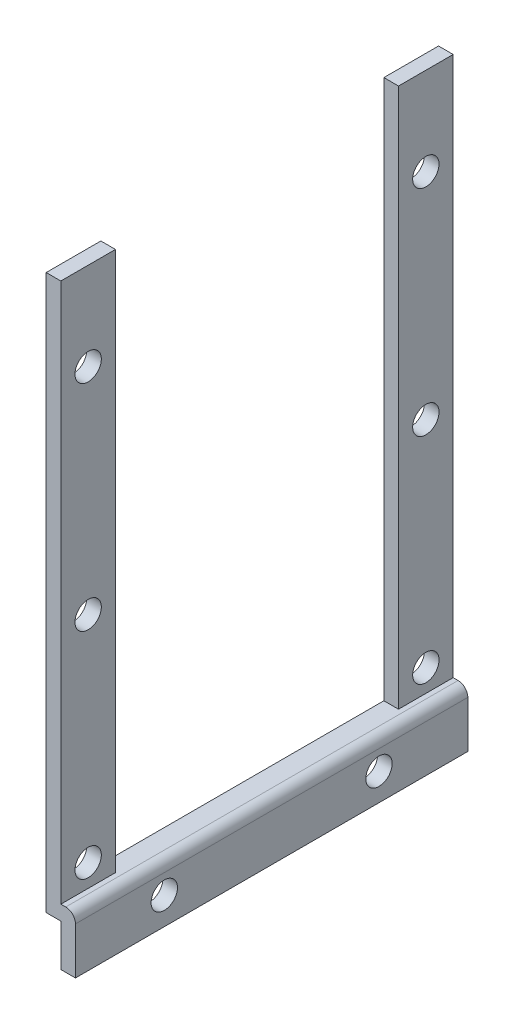
from build123d import *

# Parameters (mm, degrees)
BOSS_EXTRUDE1_DEPTH = 40.2
CUT_EXTRUDE2_REACH  = 3.5
SKETCH3_R           = 1.35
SKETCH3_W           = 29
SKETCH3_H           = 55.3
FILLET1_R           = 1
CUT_EXTRUDE3_REACH  = 5
SKETCH4_R           = 1.35


with BuildPart() as part:
    # Sketch1 → Boss-Extrude1 (new body)
    with BuildSketch(Plane.XY):
        Polygon((0, 0), (0, 4.3), (-1.5, 4.3), (-1.5, 61.1), (0, 61.1), (0, 5.8), (1.5, 5.8), (1.5, 0), align=None)
    extrude(amount=-BOSS_EXTRUDE1_DEPTH)

    # Sketch3 → Cut-Extrude2 (cut, up to next)
    with BuildSketch(Plane(origin=(0, 0, 0), x_dir=(0, 0, -1), z_dir=(1, 0, 0)), mode=Mode.PRIVATE) as cut_extrude2_sk1:
        with Locations((2.8, 8.1)):
            Circle(SKETCH3_R)
    cut_extrude2_tool1 = extrude(cut_extrude2_sk1.sketch, amount=-CUT_EXTRUDE2_REACH, mode=Mode.PRIVATE) & part.part
    add(cut_extrude2_tool1.solids().sort_by_distance((0, 8.1, -2.8))[0], mode=Mode.SUBTRACT)
    # Sketch3 → Cut-Extrude2 (cut, up to next)
    with BuildSketch(Plane(origin=(0, 0, 0), x_dir=(0, 0, -1), z_dir=(1, 0, 0)), mode=Mode.PRIVATE) as cut_extrude2_sk2:
        with Locations((37.4, 8.1)):
            Circle(SKETCH3_R)
    cut_extrude2_tool2 = extrude(cut_extrude2_sk2.sketch, amount=-CUT_EXTRUDE2_REACH, mode=Mode.PRIVATE) & part.part
    add(cut_extrude2_tool2.solids().sort_by_distance((0, 8.1, -37.4))[0], mode=Mode.SUBTRACT)
    # Sketch3 → Cut-Extrude2 (cut, up to next)
    with BuildSketch(Plane(origin=(0, 0, 0), x_dir=(0, 0, -1), z_dir=(1, 0, 0)), mode=Mode.PRIVATE) as cut_extrude2_sk3:
        with Locations((2.8, 30.1)):
            Circle(SKETCH3_R)
    cut_extrude2_tool3 = extrude(cut_extrude2_sk3.sketch, amount=-CUT_EXTRUDE2_REACH, mode=Mode.PRIVATE) & part.part
    add(cut_extrude2_tool3.solids().sort_by_distance((0, 30.1, -2.8))[0], mode=Mode.SUBTRACT)
    # Sketch3 → Cut-Extrude2 (cut, up to next)
    with BuildSketch(Plane(origin=(0, 0, 0), x_dir=(0, 0, -1), z_dir=(1, 0, 0)), mode=Mode.PRIVATE) as cut_extrude2_sk4:
        with Locations((37.4, 30.1)):
            Circle(SKETCH3_R)
    cut_extrude2_tool4 = extrude(cut_extrude2_sk4.sketch, amount=-CUT_EXTRUDE2_REACH, mode=Mode.PRIVATE) & part.part
    add(cut_extrude2_tool4.solids().sort_by_distance((0, 30.1, -37.4))[0], mode=Mode.SUBTRACT)
    # Sketch3 → Cut-Extrude2 (cut, up to next)
    with BuildSketch(Plane(origin=(0, 0, 0), x_dir=(0, 0, -1), z_dir=(1, 0, 0)), mode=Mode.PRIVATE) as cut_extrude2_sk5:
        with Locations((2.8, 52.1)):
            Circle(SKETCH3_R)
    cut_extrude2_tool5 = extrude(cut_extrude2_sk5.sketch, amount=-CUT_EXTRUDE2_REACH, mode=Mode.PRIVATE) & part.part
    add(cut_extrude2_tool5.solids().sort_by_distance((0, 52.1, -2.8))[0], mode=Mode.SUBTRACT)
    # Sketch3 → Cut-Extrude2 (cut, up to next)
    with BuildSketch(Plane(origin=(0, 0, 0), x_dir=(0, 0, -1), z_dir=(1, 0, 0)), mode=Mode.PRIVATE) as cut_extrude2_sk6:
        with Locations((37.4, 52.1)):
            Circle(SKETCH3_R)
    cut_extrude2_tool6 = extrude(cut_extrude2_sk6.sketch, amount=-CUT_EXTRUDE2_REACH, mode=Mode.PRIVATE) & part.part
    add(cut_extrude2_tool6.solids().sort_by_distance((0, 52.1, -37.4))[0], mode=Mode.SUBTRACT)
    # Sketch3 → Cut-Extrude2 (cut, up to next)
    with BuildSketch(Plane(origin=(0, 0, 0), x_dir=(0, 0, -1), z_dir=(1, 0, 0)), mode=Mode.PRIVATE) as cut_extrude2_sk7:
        with Locations((20.1, 33.45)):
            Rectangle(SKETCH3_W, SKETCH3_H)
    cut_extrude2_tool7 = extrude(cut_extrude2_sk7.sketch, amount=-CUT_EXTRUDE2_REACH, mode=Mode.PRIVATE) & part.part
    add(cut_extrude2_tool7.solids().sort_by_distance((0, 33.45, -20.1))[0], mode=Mode.SUBTRACT)

    # Fillet1
    fillet1_edges = [part.edges().sort_by_distance(p)[0] for p in [
        (1.5, 5.8, -20.1),
    ]]
    fillet(fillet1_edges, radius=FILLET1_R)

    # Sketch4 → Cut-Extrude3 (cut, up to next)
    with BuildSketch(Plane(origin=(1.5, 0, 0), x_dir=(0, 0, -1), z_dir=(1, 0, 0)), mode=Mode.PRIVATE) as cut_extrude3_sk1:
        with Locations((9.1, 2.8)):
            Circle(SKETCH4_R)
    cut_extrude3_tool1 = extrude(cut_extrude3_sk1.sketch, amount=-CUT_EXTRUDE3_REACH, mode=Mode.PRIVATE) & part.part
    add(cut_extrude3_tool1.solids().sort_by_distance((1.5, 2.8, -9.1))[0], mode=Mode.SUBTRACT)
    # Sketch4 → Cut-Extrude3 (cut, up to next)
    with BuildSketch(Plane(origin=(1.5, 0, 0), x_dir=(0, 0, -1), z_dir=(1, 0, 0)), mode=Mode.PRIVATE) as cut_extrude3_sk2:
        with Locations((31.1, 2.8)):
            Circle(SKETCH4_R)
    cut_extrude3_tool2 = extrude(cut_extrude3_sk2.sketch, amount=-CUT_EXTRUDE3_REACH, mode=Mode.PRIVATE) & part.part
    add(cut_extrude3_tool2.solids().sort_by_distance((1.5, 2.8, -31.1))[0], mode=Mode.SUBTRACT)


solid = part.part
